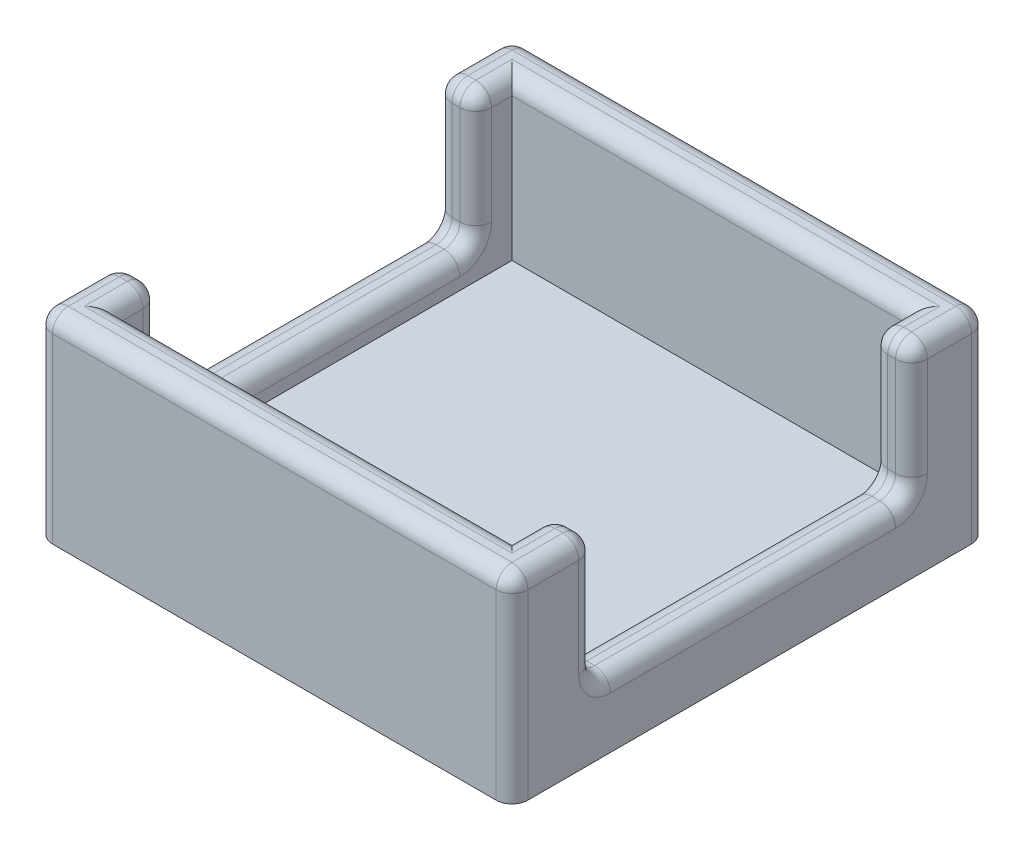
from build123d import *

# Parameters (mm, degrees)
SKETCH5_W           = 60
SKETCH5_H           = 60
BOSS_EXTRUDE3_DEPTH = 25
SHELL1_T            = -5
SKETCH6_W           = 40
SKETCH6_H           = 50
CUT_EXTRUDE2_DEPTH  = 100
FILLET2_R           = 2


with BuildPart() as part:
    # Sketch5 → Boss-Extrude3 (new body)
    with BuildSketch(Plane(origin=(0, 0, 0), x_dir=(1, 0, 0), z_dir=(0, 1, 0))):
        Rectangle(SKETCH5_W, SKETCH5_H)
    extrude(amount=BOSS_EXTRUDE3_DEPTH)

    # Shell1
    shell1_openings = [part.faces().sort_by_distance(p)[0] for p in [
        (0, 25, 0),
    ]]
    offset(amount=SHELL1_T, openings=shell1_openings, kind=Kind.INTERSECTION)

    # Sketch6 → Cut-Extrude2 (cut)
    with BuildSketch(Plane(origin=(30, 0, 0), x_dir=(0, 0, -1), z_dir=(1, 0, 0))):
        with Locations((0.42294972, 33.504960927)):
            Rectangle(SKETCH6_W, SKETCH6_H)
    extrude(amount=-CUT_EXTRUDE2_DEPTH, mode=Mode.SUBTRACT)

    # Fillet2
    fillet2_edges = [part.edges().sort_by_distance(p)[0] for p in [
        (-30, 25, -25.21147486),
        (25, 25, 22.28852514),
        (0, 25, -25),
        (-25, 25, -22.71147486),
        (0, 25, 30),
        (0, 25, 25),
        (-25, 25, 22.28852514),
        (-25, 16.752480464, 19.57705028),
        (-25, 8.504960927, -0.42294972),
        (-25, 16.752480464, -20.42294972),
        (25, 25, -22.71147486),
        (-30, 25, 24.78852514),
        (30, 25, -25.21147486),
        (30, 16.752480464, -20.42294972),
        (30, 16.752480464, 19.57705028),
        (30, 8.504960927, -0.42294972),
        (27.5, 25, -20.42294972),
        (-30, 16.752480464, -20.42294972),
        (-27.5, 25, -20.42294972),
        (-30, 8.504960927, -0.42294972),
        (-27.5, 8.504960927, -20.42294972),
        (25, 8.504960927, -0.42294972),
        (27.5, 8.504960927, -20.42294972),
        (27.5, 25, 19.57705028),
        (27.5, 8.504960927, 19.57705028),
        (-27.5, 25, 19.57705028),
        (-30, 16.752480464, 19.57705028),
        (-27.5, 8.504960927, 19.57705028),
        (25, 16.752480464, -20.42294972),
        (25, 16.752480464, 19.57705028),
        (30, 25, 24.78852514),
        (30, 12.5, 30),
        (-30, 12.5, 30),
        (-30, 12.5, -30),
        (30, 12.5, -30),
        (0, 25, -30),
    ]]
    fillet(fillet2_edges, radius=FILLET2_R)


solid = part.part
